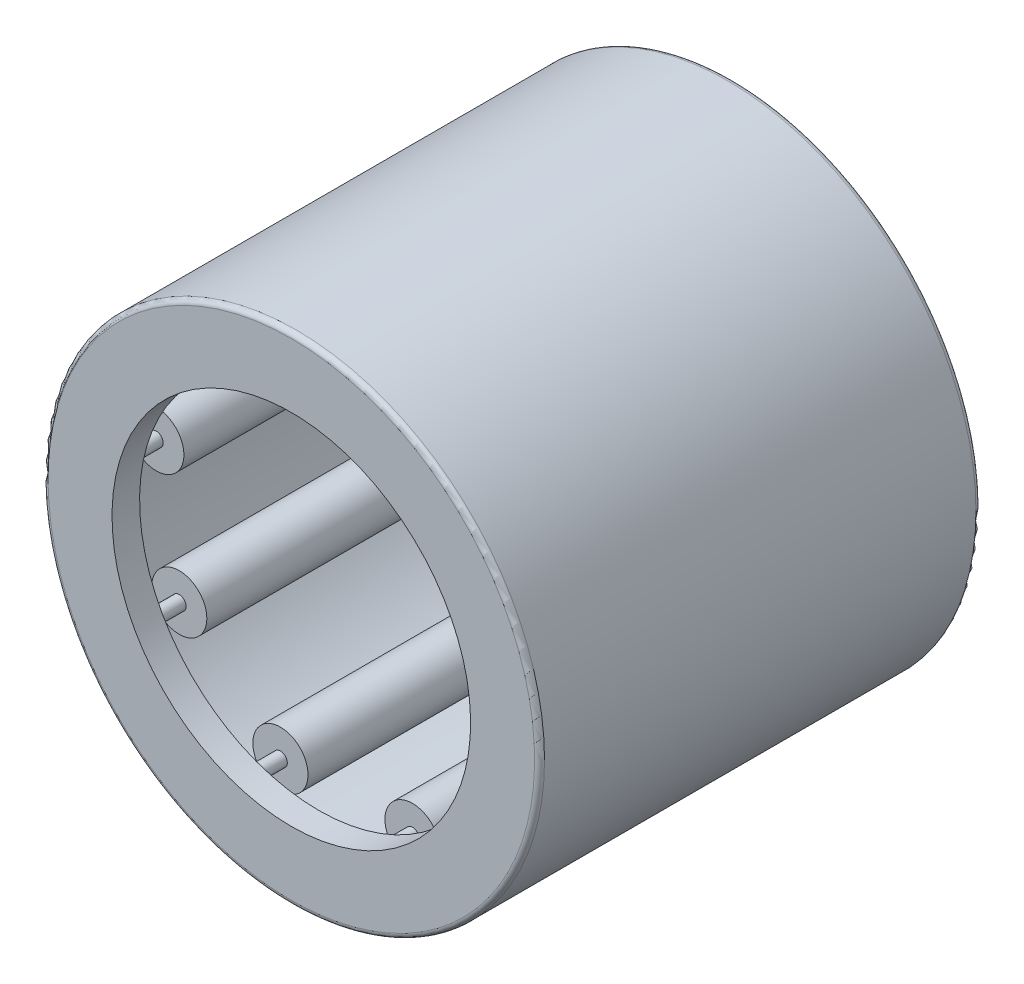
from build123d import *

# Parameters (mm, degrees)
SKETCH2_W         = 9.525
SKETCH2_H         = 0.5953125
SKETCH3_W         = 11.1125
SKETCH3_H         = 0.1984375
CIRPATTERN1_COUNT = 9
FILLET1_R         = 0.142875


with BuildPart() as part:
    # Sketch1 → Revolve1 (revolve)
    with BuildSketch(Plane(origin=(0, 0, 0), x_dir=(0, 0, -1), z_dir=(1, 0, 0))):
        Polygon((-6.35, 7.14375), (6.35, 7.14375), (6.35, 5.159375), (5.55625, 5.159375), (5.55625, 6.35), (-5.55625, 6.35), (-5.55625, 5.159375), (-6.35, 5.159375), align=None)
    revolve(axis=Axis((0, 0, 6.35), (0, 0, -1)))

    # Fillet1
    fillet1_edges = [part.edges().sort_by_distance(p)[0] for p in [
        (0, -7.14375, -6.35),
        (0, -7.14375, 6.35),
    ]]
    fillet(fillet1_edges, radius=FILLET1_R)


with BuildPart() as body_2:
    # Sketch2 → Revolve2 (revolve)
    with BuildSketch(Plane(origin=(0, 0, 0), x_dir=(0, 0, -1), z_dir=(1, 0, 0))):
        with Locations((0, 6.05234375)):
            Rectangle(SKETCH2_W, SKETCH2_H)
    revolve(axis=Axis((0, 5.55625, 4.7625), (0, 0, -1)))


with BuildPart() as body_3:
    # Sketch3 → Revolve3 (revolve)
    with BuildSketch(Plane(origin=(0, 0, 0), x_dir=(0, 0, -1), z_dir=(1, 0, 0))):
        with Locations((0, 5.65546875)):
            Rectangle(SKETCH3_W, SKETCH3_H)
    revolve(axis=Axis((0, 5.55625, 5.55625), (0, 0, -1)))


with BuildPart() as cirpattern1_1:
    # CirPattern1: pattern copy
    add(body_2.part.rotate(Axis((0, 0, -6.35), (0, 0, 1)), 1 * 360 / CIRPATTERN1_COUNT))


with BuildPart() as cirpattern1_2:
    # CirPattern1: pattern copy
    add(body_2.part.rotate(Axis((0, 0, -6.35), (0, 0, 1)), 2 * 360 / CIRPATTERN1_COUNT))


with BuildPart() as cirpattern1_3:
    # CirPattern1: pattern copy
    add(body_2.part.rotate(Axis((0, 0, -6.35), (0, 0, 1)), 3 * 360 / CIRPATTERN1_COUNT))


with BuildPart() as cirpattern1_4:
    # CirPattern1: pattern copy
    add(body_2.part.rotate(Axis((0, 0, -6.35), (0, 0, 1)), 4 * 360 / CIRPATTERN1_COUNT))


with BuildPart() as cirpattern1_5:
    # CirPattern1: pattern copy
    add(body_2.part.rotate(Axis((0, 0, -6.35), (0, 0, 1)), 5 * 360 / CIRPATTERN1_COUNT))


with BuildPart() as cirpattern1_6:
    # CirPattern1: pattern copy
    add(body_2.part.rotate(Axis((0, 0, -6.35), (0, 0, 1)), 6 * 360 / CIRPATTERN1_COUNT))


with BuildPart() as cirpattern1_7:
    # CirPattern1: pattern copy
    add(body_2.part.rotate(Axis((0, 0, -6.35), (0, 0, 1)), 7 * 360 / CIRPATTERN1_COUNT))


with BuildPart() as cirpattern1_8:
    # CirPattern1: pattern copy
    add(body_2.part.rotate(Axis((0, 0, -6.35), (0, 0, 1)), 8 * 360 / CIRPATTERN1_COUNT))


with BuildPart() as cirpattern1_9:
    # CirPattern1: pattern copy
    add(body_3.part.rotate(Axis((0, 0, -6.35), (0, 0, 1)), 1 * 360 / CIRPATTERN1_COUNT))


with BuildPart() as cirpattern1_10:
    # CirPattern1: pattern copy
    add(body_3.part.rotate(Axis((0, 0, -6.35), (0, 0, 1)), 2 * 360 / CIRPATTERN1_COUNT))


with BuildPart() as cirpattern1_11:
    # CirPattern1: pattern copy
    add(body_3.part.rotate(Axis((0, 0, -6.35), (0, 0, 1)), 3 * 360 / CIRPATTERN1_COUNT))


with BuildPart() as cirpattern1_12:
    # CirPattern1: pattern copy
    add(body_3.part.rotate(Axis((0, 0, -6.35), (0, 0, 1)), 4 * 360 / CIRPATTERN1_COUNT))


with BuildPart() as cirpattern1_13:
    # CirPattern1: pattern copy
    add(body_3.part.rotate(Axis((0, 0, -6.35), (0, 0, 1)), 5 * 360 / CIRPATTERN1_COUNT))


with BuildPart() as cirpattern1_14:
    # CirPattern1: pattern copy
    add(body_3.part.rotate(Axis((0, 0, -6.35), (0, 0, 1)), 6 * 360 / CIRPATTERN1_COUNT))


with BuildPart() as cirpattern1_15:
    # CirPattern1: pattern copy
    add(body_3.part.rotate(Axis((0, 0, -6.35), (0, 0, 1)), 7 * 360 / CIRPATTERN1_COUNT))


with BuildPart() as cirpattern1_16:
    # CirPattern1: pattern copy
    add(body_3.part.rotate(Axis((0, 0, -6.35), (0, 0, 1)), 8 * 360 / CIRPATTERN1_COUNT))


solid = Compound([part.part, body_2.part, body_3.part, cirpattern1_1.part, cirpattern1_2.part, cirpattern1_3.part, cirpattern1_4.part, cirpattern1_5.part, cirpattern1_6.part, cirpattern1_7.part, cirpattern1_8.part, cirpattern1_9.part, cirpattern1_10.part, cirpattern1_11.part, cirpattern1_12.part, cirpattern1_13.part, cirpattern1_14.part, cirpattern1_15.part, cirpattern1_16.part])
